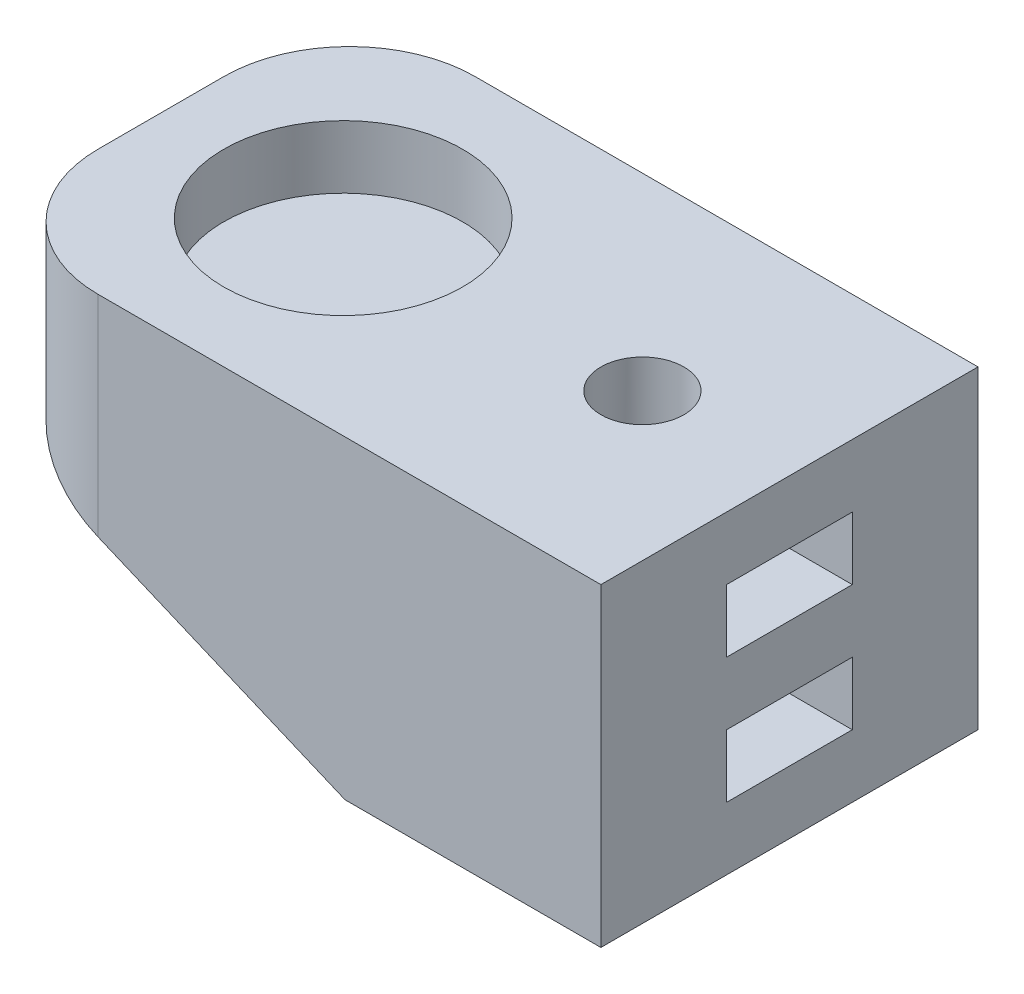
from build123d import *

# Parameters (mm, degrees)
ESQUISSE1_W                = 50
ESQUISSE1_H                = 30
BOSS_EXTRU_1_DEPTH         = 25
ESQUISSE2_R                = 9.5
ENL_V_MAT_EXTRU_1_DEPTH    = 5
ESQUISSE5_R                = 3.3
ENL_V_MAT_EXTRU_2_DEPTH    = 30
ENL_V_MAT_EXTRU_3_DEPTH    = 30
CONG_1_R                   = 10
ENL_V_START                = -5
ESQUISSE8_R                = 3.3
ENL_V_MAT_EXTRU_4_DEPTH    = 5
R_P_TITION_LIN_AIRE1_COUNT = 2
R_P_TITION_LIN_AIRE1_PITCH = 10


with BuildPart() as part:
    # Esquisse1 → Boss.-Extru.1 (new body)
    with BuildSketch(Plane(origin=(0, 0, 0), x_dir=(1, 0, 0), z_dir=(0, 1, 0))):
        with Locations((-35.541978222, 31.940035978)):
            Rectangle(ESQUISSE1_W, ESQUISSE1_H)
    extrude(amount=BOSS_EXTRU_1_DEPTH)

    # Esquisse2 → Enlèv. mat.-Extru.1 (cut)
    with BuildSketch(Plane(origin=(0, 25, 0), x_dir=(1, 0, 0), z_dir=(0, 1, 0))):
        with Locations(Location((-46.041978222, 31.940035978, 0), (0, 0, 270))):  # turned: the seam where the file's is
            Circle(ESQUISSE2_R)
    extrude(amount=-ENL_V_MAT_EXTRU_1_DEPTH, mode=Mode.SUBTRACT)

    # Esquisse5 → Enlèv. mat.-Extru.2 (cut)
    with BuildSketch(Plane(origin=(0, 25, 0), x_dir=(1, 0, 0), z_dir=(0, 1, 0))):
        with Locations(Location((-22.240136575, 31.940035978, 0), (0, 0, 270))):  # turned: the seam where the file's is
            Circle(ESQUISSE5_R)
    extrude(amount=-ENL_V_MAT_EXTRU_2_DEPTH, mode=Mode.SUBTRACT)

    # Esquisse7 → Enlèv. mat.-Extru.3 (cut)
    with BuildSketch(Plane(origin=(0, 0, -46.940035978), x_dir=(-1, 0, 0), z_dir=(0, 0, -1))):
        Polygon((30.901738287, 0), (60.541978222, 12.5), (60.541978222, 0), align=None)
    extrude(amount=-ENL_V_MAT_EXTRU_3_DEPTH, mode=Mode.SUBTRACT)

    # Congé1
    cong_1_edges = [part.edges().sort_by_distance(p)[0] for p in [
        (-60.541978222, 18.75, -46.940035978),
        (-60.541978222, 18.75, -16.940035978),
    ]]
    fillet(cong_1_edges, radius=CONG_1_R)

    # Esquisse8 → Enlèv. mat.-Extru.4 (cut)
    with BuildSketch(Plane.XZ.offset(ENL_V_START)):
        Polygon((-25.12688792, -36.940035978), (-19.353385229, -36.940035978), (-16.466633883, -31.940035978), (-19.353385229, -26.940035978), (-25.12688792, -26.940035978), (-28.013639266, -31.940035978), align=None)
        with Locations(Location((-22.240136575, -31.940035978, 0), (0, 0, 90))):  # turned: the seam where the file's is
            Circle(ESQUISSE8_R, mode=Mode.SUBTRACT)
        Polygon((-16.466633883, -31.940035978), (-19.353385229, -36.940035978), (-10.541978222, -36.940035978), (-10.541978222, -26.940035978), (-19.353385229, -26.940035978), align=None)
    enl_v_mat_extru_4 = extrude(amount=-ENL_V_MAT_EXTRU_4_DEPTH, mode=Mode.SUBTRACT)

    # Répétition linéaire1: Enlèv. mat.-Extru.4 ×2
    with Locations(*[(0, i * R_P_TITION_LIN_AIRE1_PITCH, 0) for i in range(1, R_P_TITION_LIN_AIRE1_COUNT)]):
        add(enl_v_mat_extru_4, mode=Mode.SUBTRACT)


solid = part.part
